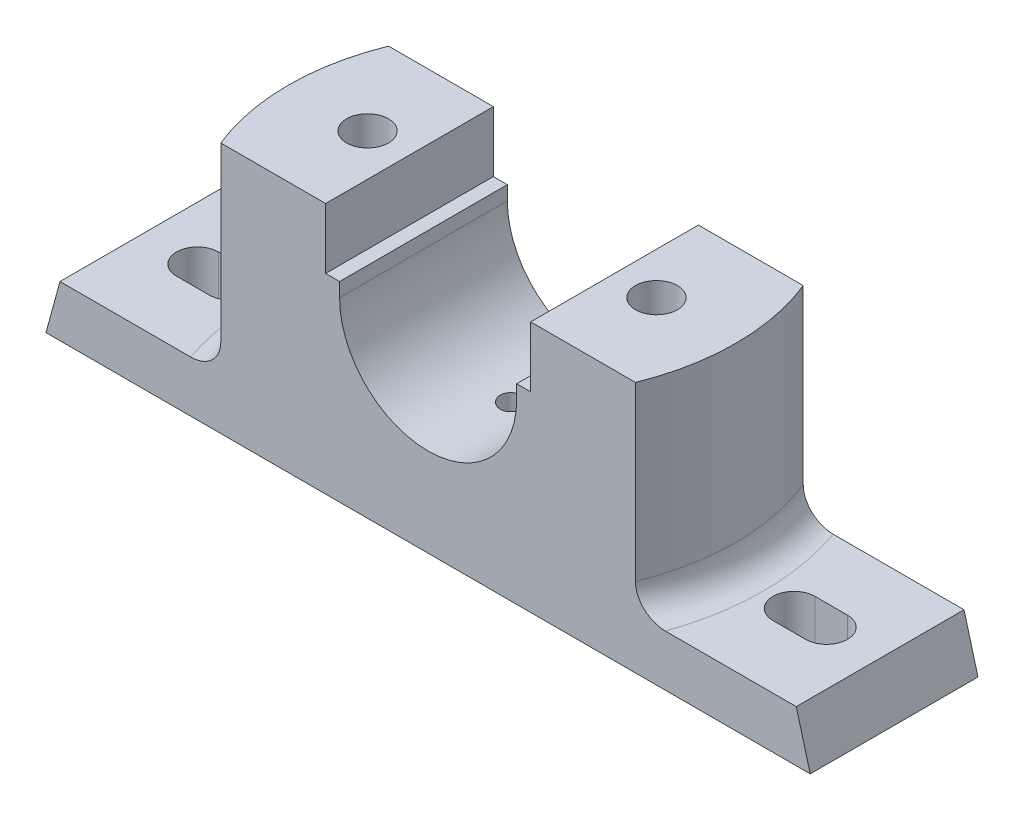
from build123d import *

# Parameters (mm, degrees)
BOSS_EXTRUDE3_DEPTH   = 18
CUT_EXTRUDE1_DEPTH    = 43
M6_TAPPED_HOLE1_D     = 5
M6_TAPPED_HOLE1_DEPTH = 6
M6_TAPPED_HOLE1_TIP   = 1.502151548
M10_TAPPED_HOLE1_D    = 9
SKETCH9_W             = 20
SKETCH9_H             = 20
CUT_EXTRUDE2_DEPTH    = 8
CUT_EXTRUDE3_DEPTH    = 11
FILLET2_R             = 6
FILLET3_R             = 6


with BuildPart() as part:
    # Sketch1 → Boss-Extrude3 (new body, symmetric)
    with BuildSketch(Plane.XY):
        with BuildLine():
            Line((-82, -43.82348407), (82, -43.82348407))
            Line((82, -43.82348407), (79, -32.82348407))
            Line((79, -32.82348407), (50, -32.82348407))
            Line((50, -32.82348407), (50, 10.17651593))
            Line((50, 10.17651593), (22, 10.17651593))
            Line((22, 10.17651593), (22, -2.82348407))
            Line((22, -2.82348407), (19, -2.82348407))
            Line((19, -2.82348407), (19, -5.82348407))
            ThreePointArc((19, -5.82348407), (0, -24.82348407), (-19, -5.82348407))
            Line((-19, -5.82348407), (-19, -2.82348407))
            Line((-19, -2.82348407), (-22, -2.82348407))
            Line((-22, -2.82348407), (-22, 10.17651593))
            Line((-22, 10.17651593), (-50, 10.17651593))
            Line((-50, 10.17651593), (-50, -32.82348407))
            Line((-50, -32.82348407), (-79, -32.82348407))
            Line((-79, -32.82348407), (-82, -43.82348407))
        make_face()
    extrude(amount=BOSS_EXTRUDE3_DEPTH, both=True)

    # Sketch3 → Cut-Extrude1 (cut)
    with BuildSketch(Plane(origin=(0, 10.17651593, 0), x_dir=(1, 0, 0), z_dir=(0, 1, 0))):
        with BuildLine():
            Line((-44.497190923, 18), (-50, 18))
            Line((-50, 18), (-50, -18))
            Line((-50, -18), (-44.497190923, -18))
            ThreePointArc((-44.497190923, -18), (-48, 0), (-44.497190923, 18))
        make_face()
    cut_extrude1 = extrude(amount=-CUT_EXTRUDE1_DEPTH, mode=Mode.SUBTRACT)

    # Mirror1: Cut-Extrude1 across plane
    add(cut_extrude1.mirror(Plane(origin=(0, 0, 0), x_dir=(0, 0, 1), z_dir=(1, 0, 0))), mode=Mode.SUBTRACT)

    # M6 Tapped Hole1
    with Locations(Plane(origin=(0, -24.82348407, 0), x_dir=(1, 0, 0), z_dir=(0, 1, 0))):
        with Locations((0, 0)):
            Hole(M6_TAPPED_HOLE1_D / 2, depth=M6_TAPPED_HOLE1_DEPTH)
            with Locations((0, 0, -(M6_TAPPED_HOLE1_DEPTH + M6_TAPPED_HOLE1_TIP / 2))):  # 118° drill point
                Cone(0, M6_TAPPED_HOLE1_D / 2, M6_TAPPED_HOLE1_TIP, mode=Mode.SUBTRACT)

    # M10 Tapped Hole1 (through all)
    with Locations(Plane(origin=(0, 10.17651593, 0), x_dir=(1, 0, 0), z_dir=(0, 1, 0))):
        with Locations((-31, 0)):
            m10_tapped_hole1 = Hole(M10_TAPPED_HOLE1_D / 2)

    # Sketch9 → Cut-Extrude2 (cut)
    with BuildSketch(Plane.XZ.offset(43.82348407)):
        with Locations((-31, 0)):
            Rectangle(SKETCH9_W, SKETCH9_H)
    cut_extrude2 = extrude(amount=-CUT_EXTRUDE2_DEPTH, mode=Mode.SUBTRACT)

    # Sketch10 → Cut-Extrude3 (cut)
    with BuildSketch(Plane.XZ.offset(43.82348407)):
        with BuildLine():
            Line((-67.5, 4.5), (-60.5, 4.5))
            ThreePointArc((-60.5, 4.5), (-56, 0), (-60.5, -4.5))
            Line((-60.5, -4.5), (-67.5, -4.5))
            ThreePointArc((-67.5, -4.5), (-72, 0), (-67.5, 4.5))
        make_face()
    cut_extrude3 = extrude(amount=-CUT_EXTRUDE3_DEPTH, mode=Mode.SUBTRACT)

    # Mirror2: M10 Tapped Hole1, Cut-Extrude2, Cut-Extrude3 across plane
    add(m10_tapped_hole1.mirror(Plane(origin=(0, 0, 0), x_dir=(0, 0, 1), z_dir=(1, 0, 0))), mode=Mode.SUBTRACT)
    add(cut_extrude2.mirror(Plane(origin=(0, 0, 0), x_dir=(0, 0, 1), z_dir=(1, 0, 0))), mode=Mode.SUBTRACT)
    add(cut_extrude3.mirror(Plane(origin=(0, 0, 0), x_dir=(0, 0, 1), z_dir=(1, 0, 0))), mode=Mode.SUBTRACT)

    # Fillet2
    fillet2_edges = [part.edges().sort_by_distance(p)[0] for p in [
        (-48, -32.82348407, 0),
    ]]
    fillet(fillet2_edges, radius=FILLET2_R)

    # Fillet3
    fillet3_edges = [part.edges().sort_by_distance(p)[0] for p in [
        (48, -32.82348407, 0),
    ]]
    fillet(fillet3_edges, radius=FILLET3_R)


solid = part.part
